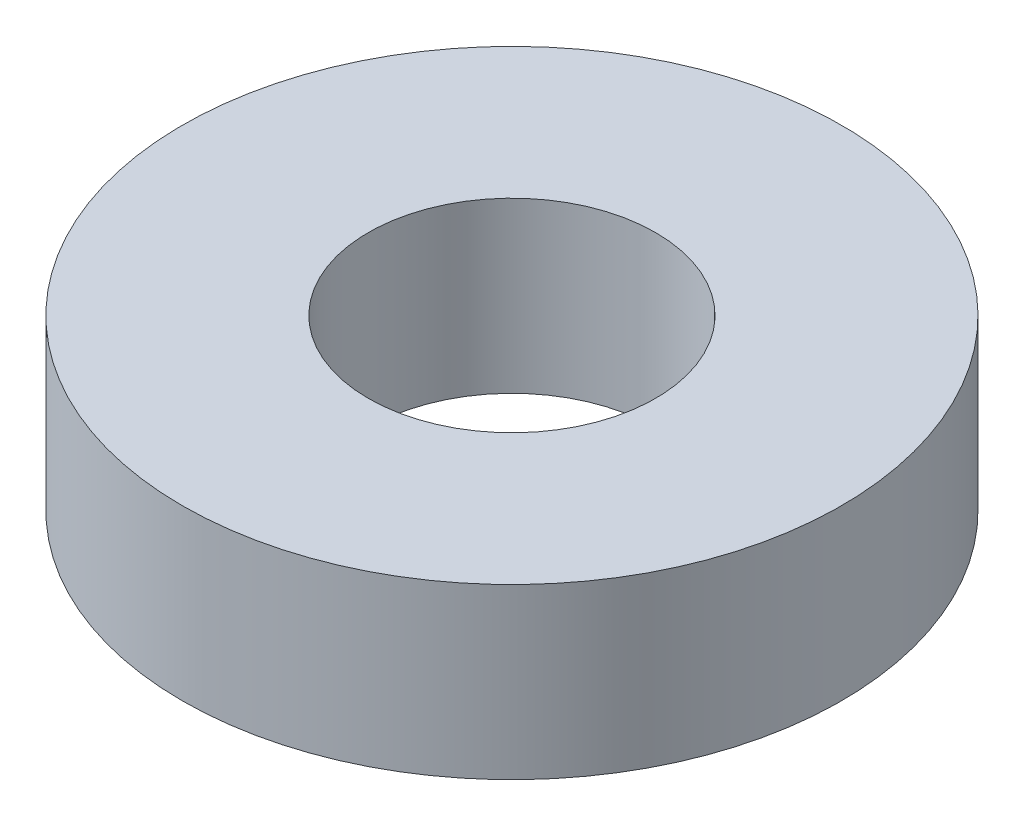
from build123d import *

# Parameters (mm, degrees)
SKETCH1_R           = 3.9
SKETCH1_R_2         = 1.7
BOSS_EXTRUDE1_DEPTH = 2


with BuildPart() as part:
    # Sketch1 → Boss-Extrude1 (new body)
    with BuildSketch(Plane(origin=(0, 0, 0), x_dir=(1, 0, 0), z_dir=(0, 1, 0))):
        Circle(SKETCH1_R)
        Circle(SKETCH1_R_2, mode=Mode.SUBTRACT)
    extrude(amount=BOSS_EXTRUDE1_DEPTH)


solid = part.part
